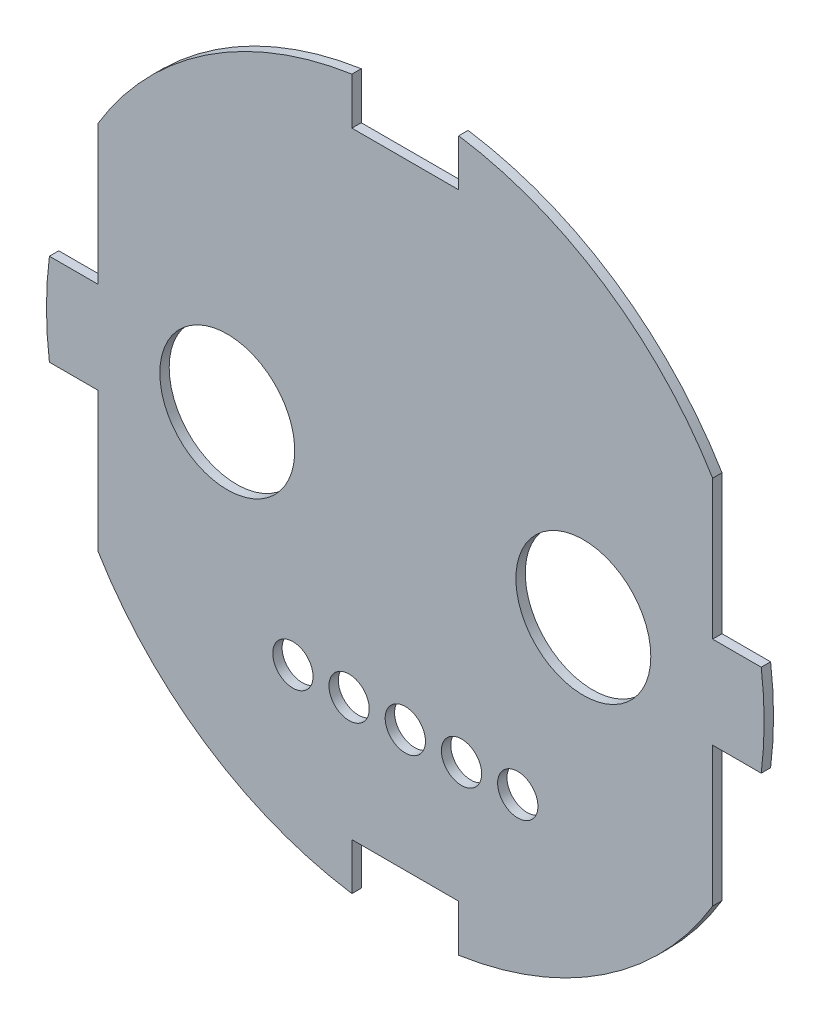
from build123d import *

# Parameters (mm, degrees)
IZIM1_R                     = 3.25
IZIM1_R_2                   = 0.725
Y_KSEKLIK_EKSTR_ZYON3_DEPTH = 0.5
IZIM2_R                     = 1.075
IZIM2_R_2                   = 0.375
IZIM2_R_3                   = 3.6
IZIM2_R_4                   = 2.9
KES_EKSTR_ZYON_NCE1_DEPTH   = 0.5


with BuildPart() as part:
    # Çizim1 → Yükseklik-Ekstrüzyon3 (new body)
    with BuildSketch(Plane.XY):
        with BuildLine():
            Line((-19.29792735, 2.8), (-16.75, 2.8))
            Line((-16.75, 2.8), (-16.75, 9.984362774))
            ThreePointArc((-16.75, 9.984362774), (-10.701322664, 16.301278884), (-2.5, 19.339079606))
            Line((-2.5, 19.339079606), (-2.5, 16.789079606))
            Line((-2.5, 16.789079606), (2.5, 16.789079606))
            Line((2.5, 16.789079606), (2.5, 19.339079606))
            ThreePointArc((2.5, 19.339079606), (10.701322664, 16.301278884), (16.75, 9.984362774))
            Line((16.75, 9.984362774), (16.75, 2.8))
            Line((16.75, 2.8), (19.29792735, 2.8))
            ThreePointArc((19.29792735, 2.8), (19.5, 0), (19.29792735, -2.8))
            Line((19.29792735, -2.8), (16.75, -2.8))
            Line((16.75, -2.8), (16.75, -9.984362774))
            ThreePointArc((16.75, -9.984362774), (10.701322664, -16.301278884), (2.5, -19.339079606))
            Line((2.5, -19.339079606), (2.5, -16.789079606))
            Line((2.5, -16.789079606), (-2.5, -16.789079606))
            Line((-2.5, -16.789079606), (-2.5, -19.339079606))
            ThreePointArc((-2.5, -19.339079606), (-10.701322664, -16.301278884), (-16.75, -9.984362774))
            Line((-16.75, -9.984362774), (-16.75, -2.8))
            Line((-16.75, -2.8), (-19.29792735, -2.8))
            ThreePointArc((-19.29792735, -2.8), (-19.5, 0), (-19.29792735, 2.8))
        make_face()
        with Locations((9.5, 0)):
            Circle(IZIM1_R, mode=Mode.SUBTRACT)
        with Locations((0, -9.939079606)):
            Circle(IZIM1_R_2, mode=Mode.SUBTRACT)
        with Locations(Location((-9.5, 0, 0), (0, 0, 180))):
            Circle(IZIM1_R, mode=Mode.SUBTRACT)
        with Locations((3, -9.939079606)):
            Circle(IZIM1_R_2, mode=Mode.SUBTRACT)
        with Locations((6, -9.939079606)):
            Circle(IZIM1_R_2, mode=Mode.SUBTRACT)
        with Locations((-3, -9.939079606)):
            Circle(IZIM1_R_2, mode=Mode.SUBTRACT)
        with Locations((-6, -9.939079606)):
            Circle(IZIM1_R_2, mode=Mode.SUBTRACT)
    extrude(amount=Y_KSEKLIK_EKSTR_ZYON3_DEPTH)

    # Çizim2 → Kes-Ekstrüzyon-İnce1 (cut)
    with BuildSketch(Plane.XY.offset(0.5)):
        with BuildLine():
            Line((-17.1, -10.080302575), (-17.1, -3.15))
            Line((-17.1, -3.15), (-19.598469328, -3.15))
            ThreePointArc((-19.598469328, -3.15), (-19.85, 0), (-19.598469328, 3.15))
            Line((-19.598469328, 3.15), (-17.1, 3.15))
            Line((-17.1, 3.15), (-17.1, 10.080302575))
            ThreePointArc((-17.1, 10.080302575), (-10.767327068, 16.675945785), (-2.15, 19.73322072))
            Line((-2.15, 19.73322072), (-2.15, 17.139079606))
            Line((-2.15, 17.139079606), (2.15, 17.139079606))
            Line((2.15, 17.139079606), (2.15, 19.73322072))
            ThreePointArc((2.15, 19.73322072), (10.767327068, 16.675945785), (17.1, 10.080302575))
            Line((17.1, 10.080302575), (17.1, 3.15))
            Line((17.1, 3.15), (19.598469328, 3.15))
            ThreePointArc((19.598469328, 3.15), (19.85, 0), (19.598469328, -3.15))
            Line((19.598469328, -3.15), (17.1, -3.15))
            Line((17.1, -3.15), (17.1, -10.080302575))
            ThreePointArc((17.1, -10.080302575), (10.767327068, -16.675945785), (2.15, -19.73322072))
            Line((2.15, -19.73322072), (2.15, -17.139079606))
            Line((2.15, -17.139079606), (-2.15, -17.139079606))
            Line((-2.15, -17.139079606), (-2.15, -19.73322072))
            ThreePointArc((-2.15, -19.73322072), (-10.767327068, -16.675945785), (-17.1, -10.080302575))
        make_face()
        with BuildLine():
            Line((-16.4, -9.887492099), (-16.4, -2.45))
            Line((-16.4, -2.45), (-18.99263015, -2.45))
            ThreePointArc((-18.99263015, -2.45), (-19.15, 0), (-18.99263015, 2.45))
            Line((-18.99263015, 2.45), (-16.4, 2.45))
            Line((-16.4, 2.45), (-16.4, 9.887492099))
            ThreePointArc((-16.4, 9.887492099), (-10.635451675, 15.925126928), (-2.85, 18.936736783))
            Line((-2.85, 18.936736783), (-2.85, 16.439079606))
            Line((-2.85, 16.439079606), (2.85, 16.439079606))
            Line((2.85, 16.439079606), (2.85, 18.936736783))
            ThreePointArc((2.85, 18.936736783), (10.635451675, 15.925126928), (16.4, 9.887492099))
            Line((16.4, 9.887492099), (16.4, 2.45))
            Line((16.4, 2.45), (18.99263015, 2.45))
            ThreePointArc((18.99263015, 2.45), (19.15, 0), (18.99263015, -2.45))
            Line((18.99263015, -2.45), (16.4, -2.45))
            Line((16.4, -2.45), (16.4, -9.887492099))
            ThreePointArc((16.4, -9.887492099), (10.635451675, -15.925126928), (2.85, -18.936736783))
            Line((2.85, -18.936736783), (2.85, -16.439079606))
            Line((2.85, -16.439079606), (-2.85, -16.439079606))
            Line((-2.85, -16.439079606), (-2.85, -18.936736783))
            ThreePointArc((-2.85, -18.936736783), (-10.635451675, -15.925126928), (-16.4, -9.887492099))
        make_face(mode=Mode.SUBTRACT)
        with Locations((-6, -9.939079606)):
            Circle(IZIM2_R)
        with Locations((-6, -9.939079606)):
            Circle(IZIM2_R_2, mode=Mode.SUBTRACT)
        with Locations((-3, -9.939079606)):
            Circle(IZIM2_R)
        with Locations((-3, -9.939079606)):
            Circle(IZIM2_R_2, mode=Mode.SUBTRACT)
        with Locations((6, -9.939079606)):
            Circle(IZIM2_R)
        with Locations((6, -9.939079606)):
            Circle(IZIM2_R_2, mode=Mode.SUBTRACT)
        with Locations((3, -9.939079606)):
            Circle(IZIM2_R)
        with Locations((3, -9.939079606)):
            Circle(IZIM2_R_2, mode=Mode.SUBTRACT)
        with Locations((-9.5, 0)):
            Circle(IZIM2_R_3)
        with Locations((-9.5, 0)):
            Circle(IZIM2_R_4, mode=Mode.SUBTRACT)
        with Locations((0, -9.939079606)):
            Circle(IZIM2_R)
        with Locations((0, -9.939079606)):
            Circle(IZIM2_R_2, mode=Mode.SUBTRACT)
        with Locations((9.5, 0)):
            Circle(IZIM2_R_3)
        with Locations((9.5, 0)):
            Circle(IZIM2_R_4, mode=Mode.SUBTRACT)
    extrude(amount=-KES_EKSTR_ZYON_NCE1_DEPTH, mode=Mode.SUBTRACT)


solid = part.part
